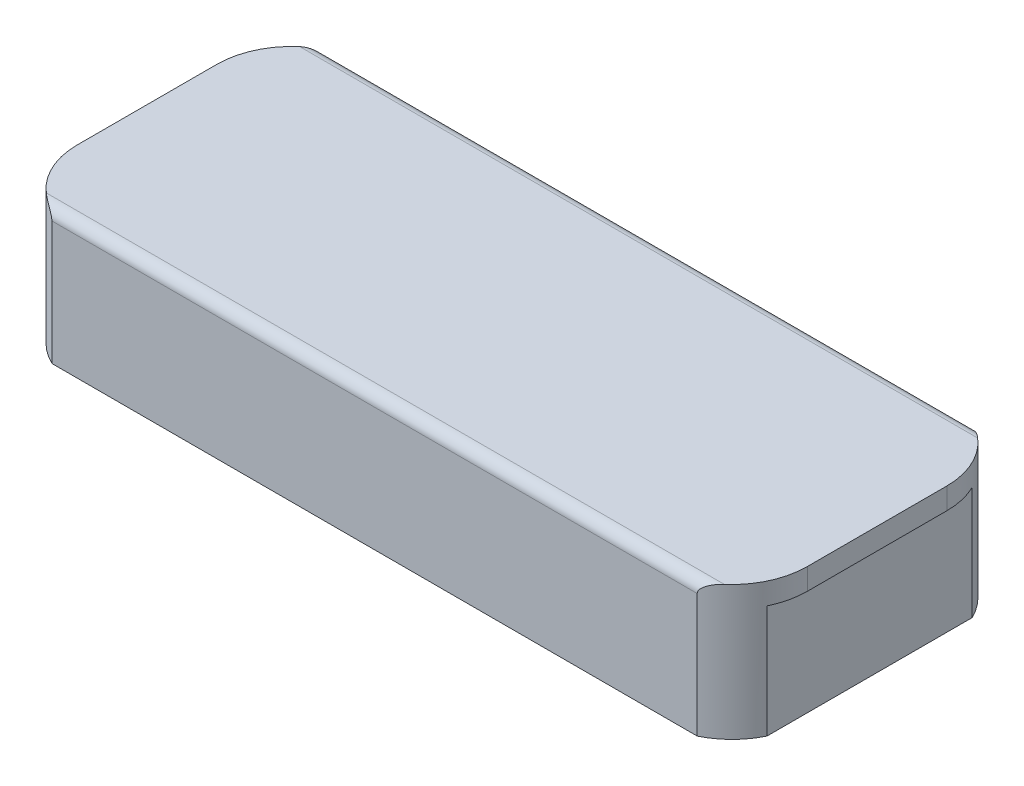
from build123d import *

# Parameters (mm, degrees)
SKETCH1_W               = 431.8
SKETCH1_H               = 171.45
BOSS_EXTRUDE1_DEPTH     = 85.725
CUT_EXTRUDE1_DEPTH      = 73.025
FILLET3_R               = 44.45
F_0_25_OFF_TOP_DEPTH    = 6.35
SKETCH4_W               = 431.8
SKETCH4_H               = 79.375
CUT_EXTRUDE_0_125_DEPTH = 4.445
SKETCH5_W               = 167.005
SKETCH5_H               = 66.675
F_1_8_IN_DEPTH          = 4.445
SKETCH6_W               = 427.355
SKETCH6_H               = 79.375
CUT_EXTRUDE5_DEPTH      = 4.445
SKETCH7_W               = 162.0012
SKETCH7_H               = 66.675
CUT_EXTRUDE6_DEPTH      = 4.445
FILLET5_R               = 6.35


with BuildPart() as part:
    # Sketch1 → Boss-Extrude1 (new body)
    with BuildSketch(Plane(origin=(0, 0, 0), x_dir=(1, 0, 0), z_dir=(0, 1, 0))):
        Rectangle(SKETCH1_W, SKETCH1_H)
    extrude(amount=BOSS_EXTRUDE1_DEPTH)

    # Sketch2 → Cut-Extrude1 (cut)
    with BuildSketch(Plane.XZ):
        with BuildLine():
            Line((162.16885638, 76.686434381), (-162.16885638, 76.686434381))
            ThreePointArc((-162.16885638, 76.686434381), (-193.771281353, 63.596281353), (-206.861434381, 31.99385638))
            Line((-206.861434381, 31.99385638), (-206.861434381, -31.99385638))
            ThreePointArc((-206.861434381, -31.99385638), (-193.771281353, -63.596281353), (-162.16885638, -76.686434381))
            Line((-162.16885638, -76.686434381), (162.16885638, -76.686434381))
            ThreePointArc((162.16885638, -76.686434381), (193.771281353, -63.596281353), (206.861434381, -31.99385638))
            Line((206.861434381, -31.99385638), (206.861434381, 31.99385638))
            ThreePointArc((206.861434381, 31.99385638), (193.771281353, 63.596281353), (162.16885638, 76.686434381))
        make_face()
    extrude(amount=-CUT_EXTRUDE1_DEPTH, mode=Mode.SUBTRACT)

    # Fillet3
    fillet3_edges = [part.edges().sort_by_distance(p)[0] for p in [
        (215.9, 42.8625, 85.725),
        (-215.9, 42.8625, 85.725),
        (-215.9, 42.8625, -85.725),
        (215.9, 42.8625, -85.725),
    ]]
    fillet(fillet3_edges, radius=FILLET3_R)

    # Sketch3 → 0.25 off top (cut)
    with BuildSketch(Plane(origin=(0, 85.725, 0), x_dir=(1, 0, 0), z_dir=(0, 1, 0))):
        with BuildLine():
            Line((215.9, -41.275), (215.9, 41.275))
            ThreePointArc((215.9, 41.275), (202.880896424, 72.705896424), (171.45, 85.725))
            Line((171.45, 85.725), (-171.45, 85.725))
            ThreePointArc((-171.45, 85.725), (-202.880896424, 72.705896424), (-215.9, 41.275))
            Line((-215.9, 41.275), (-215.9, -41.275))
            ThreePointArc((-215.9, -41.275), (-202.880896424, -72.705896424), (-171.45, -85.725))
            Line((-171.45, -85.725), (171.45, -85.725))
            ThreePointArc((171.45, -85.725), (202.880896424, -72.705896424), (215.9, -41.275))
        make_face()
    extrude(amount=-F_0_25_OFF_TOP_DEPTH, mode=Mode.SUBTRACT)

    # Sketch4 → 0.125 (cut)
    with BuildSketch(Plane.XY.offset(85.725)):
        with Locations((0, 39.6875)):
            Rectangle(SKETCH4_W, SKETCH4_H)
    extrude(amount=-CUT_EXTRUDE_0_125_DEPTH, mode=Mode.SUBTRACT)

    # Sketch5 → 1/8 in (cut)
    with BuildSketch(Plane.ZY.offset(215.9)):
        with Locations((-2.2225, 33.3375)):
            Rectangle(SKETCH5_W, SKETCH5_H)
    extrude(amount=-F_1_8_IN_DEPTH, mode=Mode.SUBTRACT)

    # Sketch6 → Cut-Extrude5 (cut)
    with BuildSketch(Plane(origin=(0, 0, -85.725), x_dir=(-1, 0, 0), z_dir=(0, 0, -1))):
        with Locations((-2.2225, 39.6875)):
            Rectangle(SKETCH6_W, SKETCH6_H)
    extrude(amount=-CUT_EXTRUDE5_DEPTH, mode=Mode.SUBTRACT)

    # Sketch7 → Cut-Extrude6 (cut)
    with BuildSketch(Plane(origin=(215.9, 0, 0), x_dir=(0, 0, -1), z_dir=(1, 0, 0))):
        with Locations((0.2794, 33.3375)):
            Rectangle(SKETCH7_W, SKETCH7_H)
    extrude(amount=-CUT_EXTRUDE6_DEPTH, mode=Mode.SUBTRACT)

    # Fillet5
    fillet5_edges = [part.edges().sort_by_distance(p)[0] for p in [
        (0, 79.375, -81.28),
        (0, 79.375, 81.28),
    ]]
    fillet(fillet5_edges, radius=FILLET5_R)


solid = part.part
